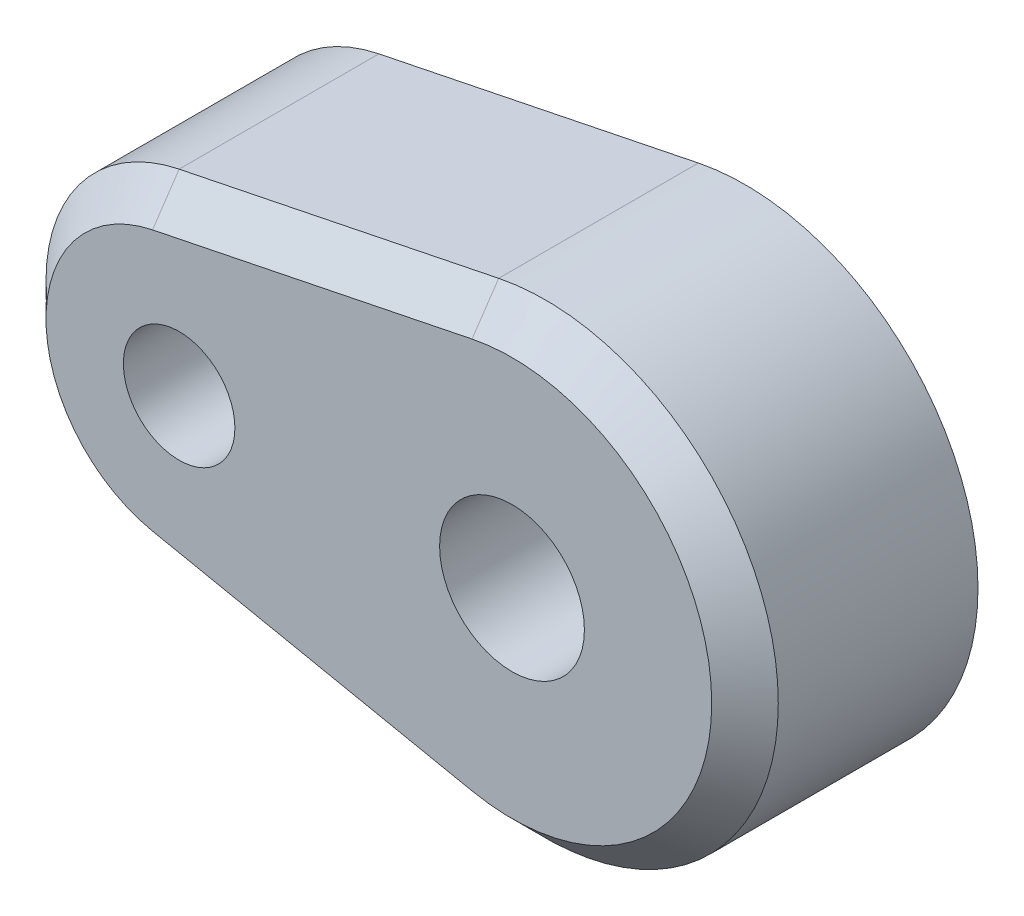
from build123d import *

# Parameters (mm, degrees)
SKETCH1_R           = 2.175
SKETCH1_R_2         = 1.675
BOSS_EXTRUDE1_DEPTH = 7
SKETCH2_R           = 5
CUT_EXTRUDE1_DEPTH  = 3.4
CHAMFER1_SIZE       = 1
FILLET1_R           = 0.5


with BuildPart() as part:
    # Sketch1 → Boss-Extrude1 (new body)
    with BuildSketch(Plane.XY):
        with BuildLine():
            Line((-1.4, 6.85857128), (-11, 4.898979486))
            ThreePointArc((-11, 4.898979486), (-15, 0), (-11, -4.898979486))
            Line((-11, -4.898979486), (-1.4, -6.85857128))
            ThreePointArc((-1.4, -6.85857128), (7, 0), (-1.4, 6.85857128))
        make_face()
        Circle(SKETCH1_R, mode=Mode.SUBTRACT)
        with Locations((-10, 0)):
            Circle(SKETCH1_R_2, mode=Mode.SUBTRACT)
    extrude(amount=BOSS_EXTRUDE1_DEPTH)

    # Sketch2 → Cut-Extrude1 (cut)
    with BuildSketch(Plane(origin=(0, 0, 0), x_dir=(-1, 0, 0), z_dir=(0, 0, -1))):
        Circle(SKETCH2_R)
    extrude(amount=-CUT_EXTRUDE1_DEPTH, mode=Mode.SUBTRACT)

    # Chamfer1
    chamfer1_edges = [part.edges().sort_by_distance(p)[0] for p in [
        (-15, 0, 7),
        (-6.2, -5.878775383, 7),
        (7, 0, 7),
        (-6.2, 5.878775383, 7),
    ]]
    chamfer(chamfer1_edges, length=CHAMFER1_SIZE)

    # Fillet1
    fillet1_edges = [part.edges().sort_by_distance(p)[0] for p in [
        (-11.675, 0, 0),
        (5, 0, 0),
    ]]
    fillet(fillet1_edges, radius=FILLET1_R)


solid = part.part
